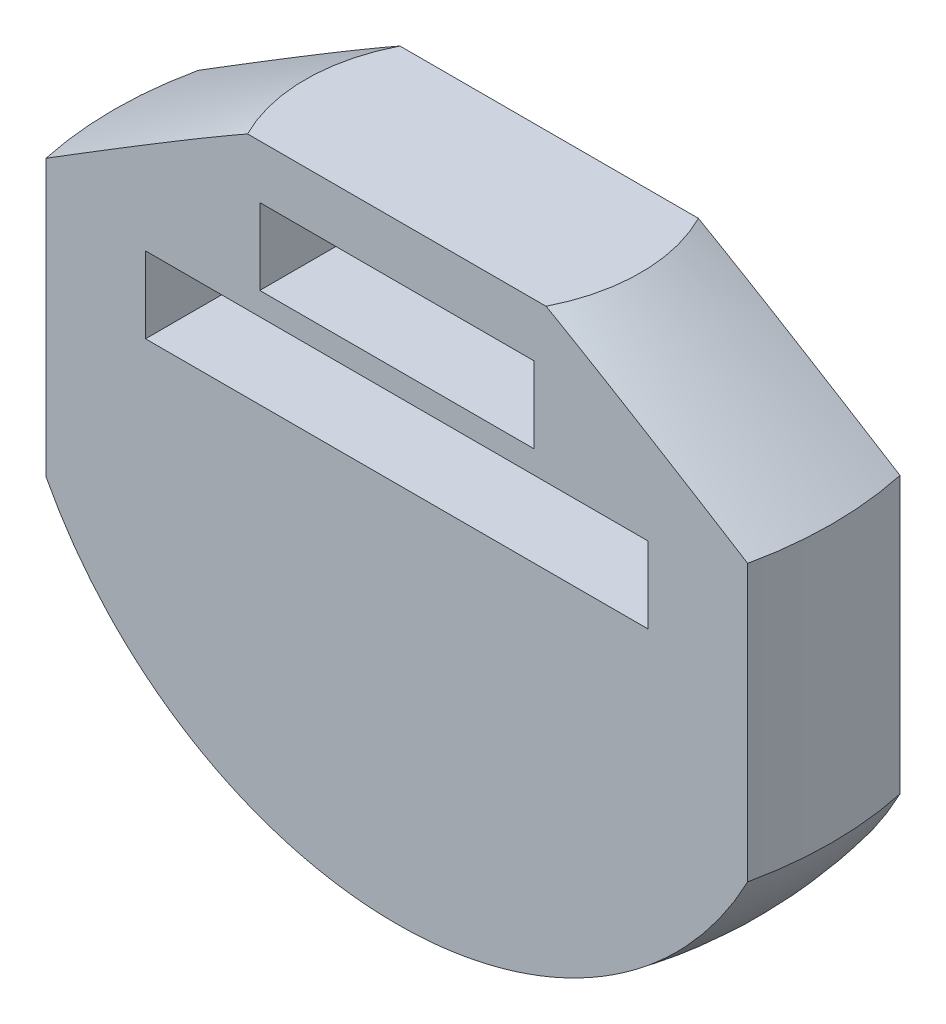
from build123d import *

# Parameters (mm, degrees)
BOSS_EXTRUDE2_DEPTH     = 5
CUT_EXTRUDE1_DEPTH      = 36.816126256
CUT_EXTRUDE1_DEPTH_BACK = 36.816126256
SKETCH2_W               = 18
SKETCH2_H               = 5
SKETCH2_W_2             = 33


with BuildPart() as part:
    # Sketch1 → Boss-Extrude2 (new, symmetric)
    with BuildSketch(Plane.XY):
        with BuildLine():
            Line((-23.57, 6), (-23.57, -12.112188076))
            ThreePointArc((-23.57, -12.112188076), (-13.807190445, -22.618830474), (0, -26.5))
            Line((0, -26.5), (0, 14))
            Line((0, 14), (-11, 14))
            Line((-11, 14), (-23.57, 6))
        make_face()
    boss_extrude2 = extrude(amount=BOSS_EXTRUDE2_DEPTH, both=True)

    # Mirror2: Boss-Extrude2 across plane
    add(boss_extrude2.mirror(Plane(origin=(0, 0, 0), x_dir=(0, 0, 1), z_dir=(1, 0, 0))))

    # Sketch1_6 → Cut-Revolve2 (revolve, cut)
    with BuildSketch(Plane.XY):
        with BuildLine():
            ThreePointArc((0, -26.5), (-13.807190445, -22.618830474), (-23.57, -12.112188076))
            Line((-23.57, -12.112188076), (-23.57, 6))
            Line((-23.57, 6), (-11, 14))
            Line((-11, 14), (0, 14))
            Line((0, 14), (0, 39.736431601))
            ThreePointArc((0, 39.736431601), (-39.736431601, 0), (0, -39.736431601))
            Line((0, -39.736431601), (0, -26.5))
        make_face()
    revolve(axis=Axis((0, 0, 0), (0, 1, 0)), mode=Mode.SUBTRACT)

    # Sketch2 → Cut-Extrude1 (cut, two sides: drawn at the far end of the back side and taken through both)
    with BuildSketch(Plane.XY.offset(-CUT_EXTRUDE1_DEPTH_BACK)):
        with Locations((0, 8)):
            Rectangle(SKETCH2_W, SKETCH2_H)
        with Locations((0, 1.5)):
            Rectangle(SKETCH2_W_2, SKETCH2_H)
    extrude(amount=CUT_EXTRUDE1_DEPTH + CUT_EXTRUDE1_DEPTH_BACK, mode=Mode.SUBTRACT)


solid = part.part
